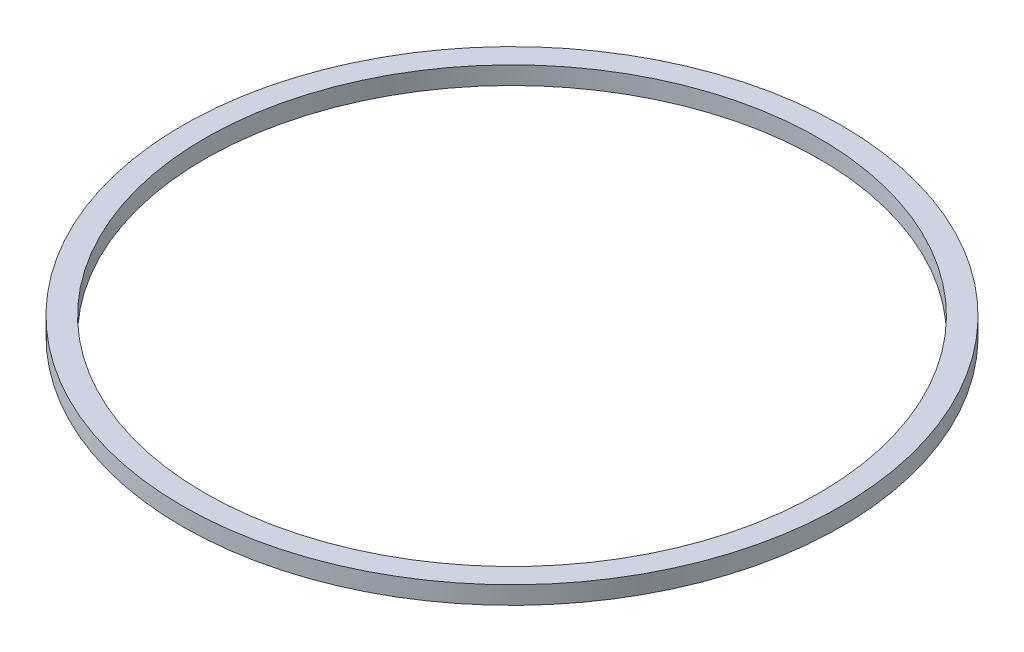
from build123d import *

# Parameters (mm, degrees)
SKETCH1_R           = 73.75
BOSS_EXTRUDE1_DEPTH = 4
SKETCH3_R           = 68.75
CUT_EXTRUDE1_DEPTH  = 70


with BuildPart() as part:
    # Sketch1 → Boss-Extrude1 (new body)
    with BuildSketch(Plane(origin=(0, 0, 0), x_dir=(1, 0, 0), z_dir=(0, 1, 0))):
        Circle(SKETCH1_R)
    extrude(amount=BOSS_EXTRUDE1_DEPTH)

    # Sketch3 → Cut-Extrude1 (cut)
    with BuildSketch(Plane(origin=(0, 4, 0), x_dir=(1, 0, 0), z_dir=(0, 1, 0))):
        Circle(SKETCH3_R)
    extrude(amount=-CUT_EXTRUDE1_DEPTH, mode=Mode.SUBTRACT)


solid = part.part
